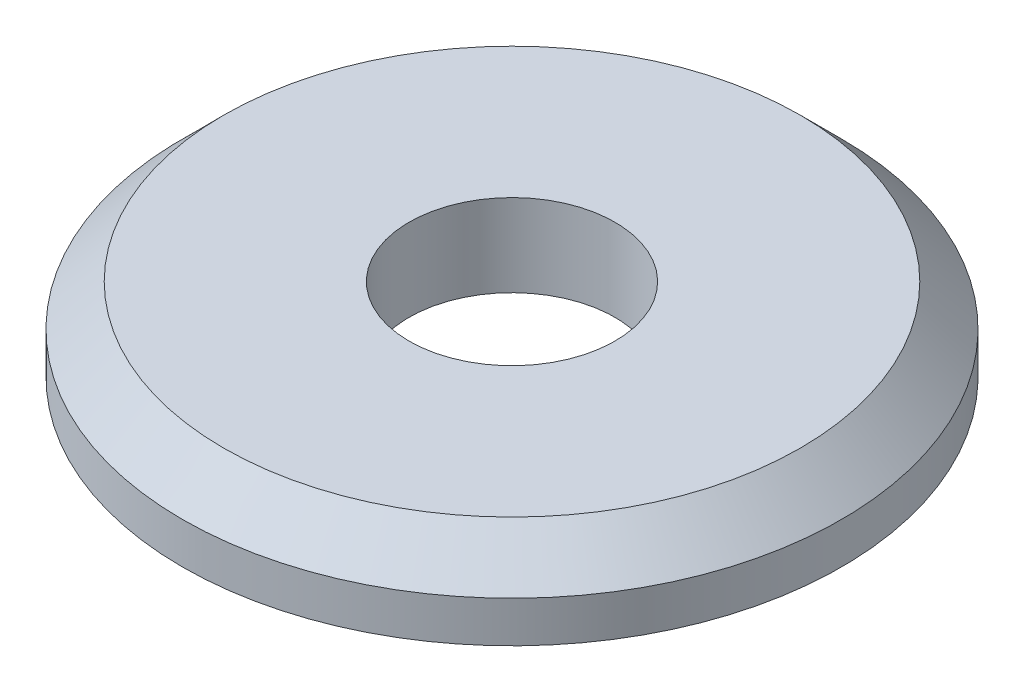
from build123d import *

# Parameters (mm, degrees)
SKETCH1_R           = 8
BOSS_EXTRUDE1_DEPTH = 2
CHAMFER1_SIZE       = 1
SKETCH2_R           = 2.5
CUT_EXTRUDE1_DEPTH  = 2


with BuildPart() as part:
    # Sketch1 → Boss-Extrude1 (new body)
    with BuildSketch(Plane(origin=(0, 0, 0), x_dir=(1, 0, 0), z_dir=(0, 1, 0))):
        Circle(SKETCH1_R)
    extrude(amount=BOSS_EXTRUDE1_DEPTH)

    # Chamfer1
    chamfer1_edges = [part.edges().sort_by_distance(p)[0] for p in [
        (-8, 2, 0),
    ]]
    chamfer(chamfer1_edges, length=CHAMFER1_SIZE)

    # Sketch2 → Cut-Extrude1 (cut)
    with BuildSketch(Plane(origin=(0, 2, 0), x_dir=(1, 0, 0), z_dir=(0, 1, 0))):
        Circle(SKETCH2_R)
    extrude(amount=-CUT_EXTRUDE1_DEPTH, mode=Mode.SUBTRACT)


solid = part.part
